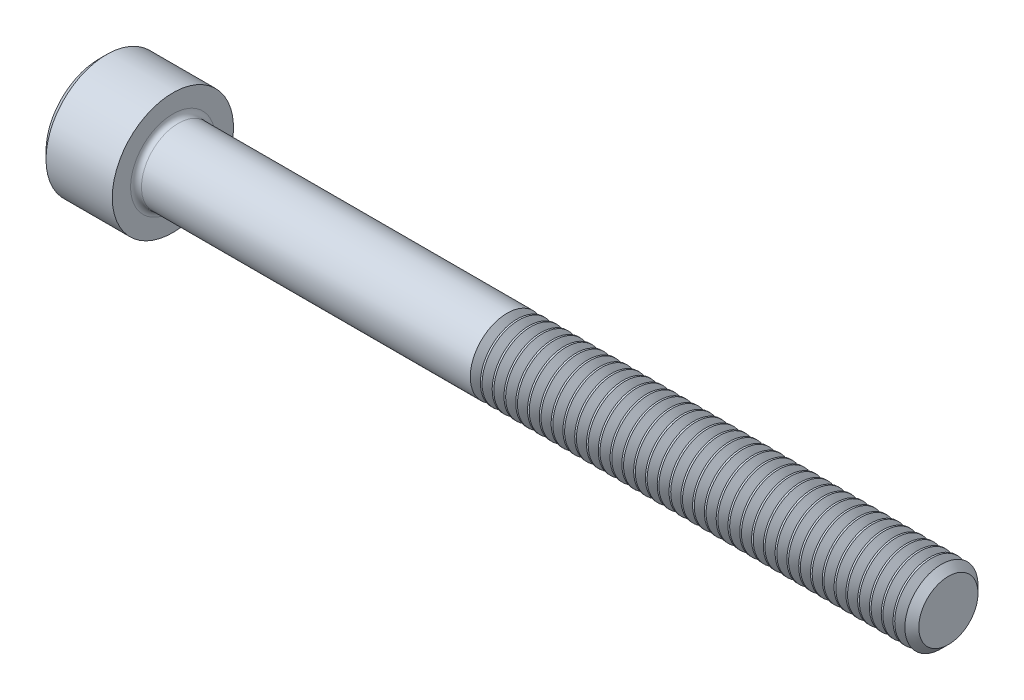
from build123d import *

# Parameters (mm, degrees)
FILLET1_R       = 0.3556
HEX_2_DEPTH     = 2.286
THDSCHPAT_COUNT = 37
THDSCHPAT_PITCH = 0.772297297


with BuildPart() as part:
    # BodySke → Base-Revolve (revolve)
    with BuildSketch(Plane.XY):
        Polygon((0, 0), (0, 3.48615), (0.4826, 3.96875), (4.826, 3.96875), (4.826, 2.413), (55.15356, 2.413), (55.626, 1.94056), (55.626, 0), align=None)
    revolve(axis=Axis((-31.75, 0, 0), (1, 0, 0)))

    # Fillet1
    fillet1_edges = [part.edges().sort_by_distance(p)[0] for p in [
        (4.826, -2.413, 0),
    ]]
    fillet(fillet1_edges, radius=FILLET1_R)

    # Sketch2 → Hex-PreBroach (revolve, cut)
    with BuildSketch(Plane.XY):
        Polygon((0, 1.98501), (2.286, 1.98501), (3.432046058, 0), (0, 0), align=None)
    revolve(axis=Axis((0, 0, 0), (1, 0, 0)), mode=Mode.SUBTRACT)

    # Sketch3 → Hex 2 (cut)
    with BuildSketch(Plane(origin=(0, 0, 0), x_dir=(0, 0.5, 0.866025404), z_dir=(-1, 0, 0))):
        Polygon((1.146046058, 1.98501), (-1.146046058, 1.98501), (-2.292092116, 0), (-1.146046058, -1.98501), (1.146046058, -1.98501), (2.292092116, 0), align=None)
    extrude(amount=-HEX_2_DEPTH, mode=Mode.SUBTRACT)

    # ThdSchSke → ThreadSchematic (revolve, cut)
    with BuildSketch(Plane.XY):
        Polygon((27.051, -1.94056), (26.720193951, -2.413), (26.720193951, -3.01625), (27.381806049, -3.01625), (27.381806049, -2.413), align=None)
    threadschematic = revolve(axis=Axis((-3.175, 0, 0), (1, 0, 0)), mode=Mode.SUBTRACT)

    # ThdSchPat: ThreadSchematic ×37
    with Locations(*[(i * THDSCHPAT_PITCH, 0, 0) for i in range(1, THDSCHPAT_COUNT)]):
        add(threadschematic, mode=Mode.SUBTRACT)


solid = part.part
